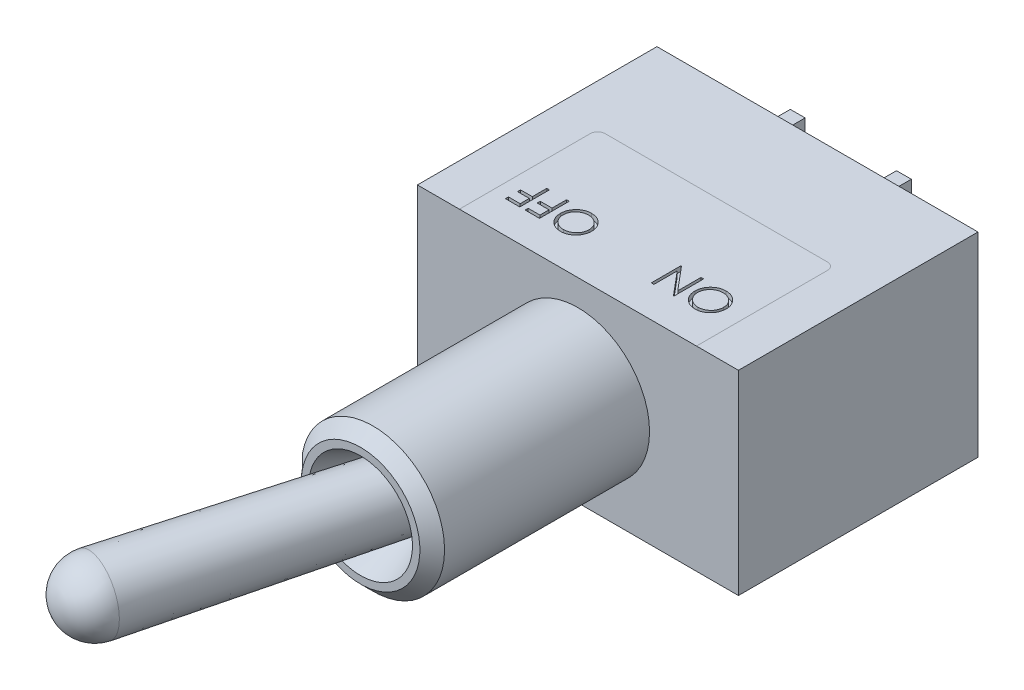
from build123d import *
from build123d.topology import SkipClean

# Parameters (mm, degrees)
SKETCH1_W                = 13
SKETCH1_H                = 7.9
BOSS_EXTRUDE1_DEPTH      = 9.7
SKETCH1_3_R              = 2.9
BOSS_EXTRUDE2_DEPTH      = 8.8
SKETCH10_W               = 1
SKETCH10_H               = 1
CUT_EXTRUDE2_DEPTH       = 13.326495852
CUT_EXTRUDE1_DEPTH       = 0.2
BOSS_EXTRUDE3_DEPTH      = 0.3
BOSS_EXTRUDE3_DEPTH_BACK = 0.3
BOSS_EXTRUDE4_DEPTH      = 0.3
BOSS_EXTRUDE4_DEPTH_BACK = 0.3


with BuildPart() as part:
    # Sketch1 → Boss-Extrude1 (new body)
    with BuildSketch(Plane.XY):
        Rectangle(SKETCH1_W, SKETCH1_H)
    extrude(amount=-BOSS_EXTRUDE1_DEPTH)

    # Sketch1_3 → Boss-Extrude2 (add)
    with BuildSketch(Plane.XY):
        Circle(SKETCH1_3_R)
    extrude(amount=BOSS_EXTRUDE2_DEPTH)

    # Sketch7 → Cut-Revolve1 (revolve, cut)
    with BuildSketch(Plane(origin=(0, 0, 0), x_dir=(1, 0, 0), z_dir=(0, 1, 0))):
        Polygon((2.4, -8.8), (2.9, -8.3), (2.9, -8.8), align=None)
        with BuildLine():
            Line((1.4, -7.2), (2.1, -8.8))
            Line((2.1, -8.8), (0, -8.8))
            Line((0, -8.8), (0, -7.5))
            ThreePointArc((0, -7.5), (0.715891053, -7.424158248), (1.4, -7.2))
        make_face()
    revolve(axis=Axis((0, 0, 0), (0, 0, 1)), mode=Mode.SUBTRACT)

    # Sketch10 → Cut-Extrude2 (cut, through all)
    with BuildSketch(Plane.XY):
        with Locations((-2.9, 0)):
            Rectangle(SKETCH10_W, SKETCH10_H)
    extrude(amount=CUT_EXTRUDE2_DEPTH, mode=Mode.SUBTRACT)

    # Sketch2 → Revolve1 (revolve)
    with SkipClean():  # the faces are left unmerged after this step: merging them gives an invalid solid
        with BuildSketch(Plane(origin=(0, 0, 0), x_dir=(1, 0, 0), z_dir=(0, 1, 0))):
            with BuildLine():
                Line((-3.96418553, -16.58535718), (-1.255703574, -6.863535241))
                Line((-1.255703574, -6.863535241), (-0.983882184, -5.887859866))
                Line((-0.983882184, -5.887859866), (0.258819045, -6.234074174))
                Line((0.258819045, -6.234074174), (0, -7.2))
                Line((0, -7.2), (-2.974236036, -18.3))
                ThreePointArc((-2.974236036, -18.3), (-3.824324938, -17.647703843), (-3.96418553, -16.58535718))
            make_face()
        revolve(axis=Axis((0, 0, 7.2), (-0.2588190451025213, 0, 0.9659258262890682)))

    # Sketch3 → Cut-Extrude1 (cut)
    # profile 1 of 5: a face of its own
    with SkipClean():  # the faces are left unmerged after this step: merging them gives an invalid solid
        with BuildSketch(Plane(origin=(0, 3.95, 0), x_dir=(1, 0, 0), z_dir=(0, 1, 0))):
            with BuildLine():
                add(Edge.make_bspline(
                    [(3.476923077, 1.269230769), (3.454700737, 1.269784093), (3.411054227, 1.270870866), (3.346966785, 1.279464434), (3.285600478, 1.293608936), (3.226918653, 1.313582637), (3.171149539, 1.339480906), (3.118116816, 1.370921984), (3.068002774, 1.408214878), (3.020937029, 1.450474317), (2.978158817, 1.49692627), (2.94093484, 1.546795714), (2.909253765, 1.599078916), (2.883369194, 1.654116364), (2.863029992, 1.711662331), (2.849002855, 1.772059631), (2.840040589, 1.83490719), (2.838992979, 1.877773606), (2.838461538, 1.899519231)],
                    knots=[0, 0, 0, 0, 1.065027606, 2.091802087, 3.093458616, 4.079833113, 5.057734272, 6.036020118, 7.030157768, 8.047461502, 9.064242947, 10.052216774, 11.02588392, 11.989864716, 12.962978571, 13.945936472, 14.957997893, 16, 16, 16, 16], degree=3))
                add(Edge.make_bspline(
                    [(2.838461538, 1.899519231), (2.838993157, 1.921104548), (2.840041038, 1.963651708), (2.849010138, 2.026102226), (2.863092546, 2.086128412), (2.883117579, 2.143590653), (2.909021217, 2.198517163), (2.940752143, 2.250836946), (2.977892488, 2.300851803), (3.020495307, 2.347529881), (3.067017934, 2.390312039), (3.116579271, 2.42813211), (3.169119513, 2.459638397), (3.223818636, 2.48590992), (3.281221016, 2.50580709), (3.34092181, 2.520306518), (3.403259527, 2.529178462), (3.445724032, 2.530233156), (3.467307692, 2.530769231)],
                    knots=[0, 0, 0, 0, 1.043683505, 2.0572211, 3.045299494, 4.022276905, 4.994977706, 5.977452478, 6.97747046, 8.003698437, 9.029677512, 10.031249186, 11.013723958, 11.988083691, 12.9614021, 13.946617861, 14.956316495, 16, 16, 16, 16], degree=3))
                add(Edge.make_bspline(
                    [(3.467307692, 2.530769231), (3.489053216, 2.530238084), (3.531919431, 2.529191051), (3.594845804, 2.520213548), (3.655286124, 2.506180278), (3.713054294, 2.486106187), (3.768169272, 2.460260448), (3.820625727, 2.428499874), (3.870486694, 2.3910744), (3.91724478, 2.348505037), (3.95997535, 2.30207162), (3.997559354, 2.252575357), (4.029136821, 2.200486988), (4.05499347, 2.146021228), (4.075445095, 2.089318864), (4.089402325, 2.030023216), (4.098431444, 1.96846655), (4.099472011, 1.926554736), (4.1, 1.905288462)],
                    knots=[0, 0, 0, 0, 1.053167129, 2.076072758, 3.073341244, 4.055601477, 5.033424535, 6.017524495, 7.021518915, 8.049444456, 9.077120685, 10.074910483, 11.055688766, 12.022980584, 12.991883888, 13.970269434, 14.970104079, 16, 16, 16, 16], degree=3))
                add(Edge.make_bspline(
                    [(4.1, 1.905288462), (4.099816864, 1.891014338), (4.099452904, 1.862646166), (4.095064708, 1.820521435), (4.088709965, 1.779069612), (4.079554983, 1.738430038), (4.067745833, 1.698596078), (4.053193059, 1.659649193), (4.036515575, 1.621268577), (4.016658726, 1.58418468), (3.994994309, 1.548339296), (3.97137144, 1.514180642), (3.945625408, 1.482318884), (3.918123989, 1.452242054), (3.888486503, 1.424463496), (3.857158991, 1.398377574), (3.823977536, 1.374254318), (3.788889659, 1.352600383), (3.752789938, 1.332710982), (3.71541647, 1.316104968), (3.677557796, 1.301427479), (3.638880443, 1.289763228), (3.599473877, 1.280480747), (3.559288836, 1.274173536), (3.51836671, 1.269775589), (3.490797058, 1.269413157), (3.476923077, 1.269230769)],
                    knots=[0, 0, 0, 0, 1.037115869, 2.061148057, 3.07517727, 4.084041727, 5.086514338, 6.092668487, 7.104487461, 8.125783165, 9.147610153, 10.147694368, 11.141876323, 12.122903372, 13.107606018, 14.091946891, 15.084523921, 16.086505767, 17.087268121, 18.077809654, 19.05670789, 20.036870126, 21.011670792, 21.99694167, 22.991993299, 24, 24, 24, 24], degree=3))
            make_face()
            with BuildLine():
                add(Edge.make_bspline(
                    [(3.471634615, 1.392307692), (3.483022661, 1.392445961), (3.505689883, 1.392721177), (3.539384899, 1.396368992), (3.572648837, 1.40152573), (3.605408617, 1.40903429), (3.637693536, 1.41865513), (3.669539428, 1.430535491), (3.700974733, 1.444405007), (3.731711991, 1.460504398), (3.761260316, 1.478550143), (3.789797252, 1.497576351), (3.816232939, 1.518661401), (3.841077991, 1.541023382), (3.864272131, 1.564970188), (3.885818458, 1.590325412), (3.905695744, 1.617203845), (3.923665728, 1.645493495), (3.939657561, 1.675036785), (3.953975734, 1.705268875), (3.965844949, 1.736545082), (3.975247137, 1.768670225), (3.983227439, 1.801502738), (3.988233276, 1.835221504), (3.991916041, 1.869710283), (3.992176137, 1.89301848), (3.992307692, 1.904807692)],
                    knots=[0, 0, 0, 0, 1.008431664, 2.007222653, 2.999229743, 3.989431819, 4.982149843, 5.98167215, 6.998687425, 8.024288174, 9.053028776, 10.065052016, 11.06063401, 12.045759335, 13.024701188, 14.011819507, 14.991481775, 15.984022113, 16.97831254, 17.965966747, 18.945551853, 19.938269878, 20.93007375, 21.936103907, 22.956087853, 24, 24, 24, 24], degree=3))
                add(Edge.make_bspline(
                    [(3.992307692, 1.904807692), (3.991869597, 1.922142917), (3.991007727, 1.956246666), (3.983493686, 2.006229939), (3.971827394, 2.054312747), (3.954913476, 2.100208499), (3.933336435, 2.144121856), (3.907016825, 2.185881922), (3.875713615, 2.225476381), (3.840176831, 2.262610489), (3.801318294, 2.296490768), (3.760076024, 2.326271711), (3.716776314, 2.351336183), (3.671668732, 2.372289519), (3.624368158, 2.38807489), (3.575177864, 2.399329852), (3.524096763, 2.406624513), (3.489287953, 2.407332998), (3.471634615, 2.407692308)],
                    knots=[0, 0, 0, 0, 1.032022337, 2.030307203, 3.003823408, 3.974715386, 4.937372378, 5.913284036, 6.909147208, 7.938749767, 8.970518239, 9.975863271, 10.963918693, 11.946286286, 12.933361397, 13.927862637, 14.949112547, 16, 16, 16, 16], degree=3))
                add(Edge.make_bspline(
                    [(3.471634615, 2.407692308), (3.459768454, 2.40752941), (3.436234291, 2.407206334), (3.401230801, 2.40394771), (3.366854656, 2.398732615), (3.333169482, 2.391186727), (3.300130734, 2.381868113), (3.267839625, 2.370307536), (3.236301172, 2.356455862), (3.2053818, 2.34099386), (3.175751222, 2.323555623), (3.147745925, 2.304395274), (3.121181742, 2.284025846), (3.096382039, 2.26182581), (3.07328473, 2.238081007), (3.052123486, 2.212618508), (3.032255468, 2.185941428), (3.014411522, 2.157658968), (2.998200312, 2.128349444), (2.984302756, 2.098029345), (2.97242672, 2.066890707), (2.962855142, 2.034902801), (2.955350499, 2.002139682), (2.950180528, 1.968553893), (2.946563843, 1.934213591), (2.946291255, 1.91098712), (2.946153846, 1.899278846)],
                    knots=[0, 0, 0, 0, 1.047362266, 2.077233941, 3.100744636, 4.115120168, 5.122788643, 6.129711893, 7.140355774, 8.162227187, 9.180148637, 10.17298275, 11.156396779, 12.133377858, 13.108923632, 14.078087502, 15.054351192, 16.043448276, 17.028082865, 18.009331763, 18.985518559, 19.968016174, 20.954783108, 21.950335389, 22.966780876, 24, 24, 24, 24], degree=3))
                add(Edge.make_bspline(
                    [(2.946153846, 1.899278846), (2.946291371, 1.887650673), (2.946564176, 1.86458405), (2.950178738, 1.830483198), (2.955356187, 1.79713924), (2.962817687, 1.764683079), (2.972434882, 1.733106442), (2.984293396, 1.702438987), (2.998276923, 1.672566456), (3.014325475, 1.643562724), (3.032365117, 1.615731284), (3.052077684, 1.589125117), (3.073801996, 1.564241639), (3.096923046, 1.540474962), (3.12199671, 1.518300451), (3.149027384, 1.497803857), (3.177341962, 1.478061387), (3.207581059, 1.460589919), (3.238676041, 1.444371097), (3.270615673, 1.430545466), (3.303000551, 1.418602359), (3.335873929, 1.409075725), (3.36917902, 1.401518436), (3.402925078, 1.396370861), (3.437099574, 1.392720785), (3.460086404, 1.392445827), (3.471634615, 1.392307692)],
                    knots=[0, 0, 0, 0, 1.02988216, 2.042960975, 3.035124439, 4.018561492, 4.99104521, 5.957523397, 6.929462691, 7.91146347, 8.892205782, 9.866320947, 10.842813644, 11.816825305, 12.802668543, 13.805243666, 14.821427616, 15.858893029, 16.897256944, 17.927432741, 18.940436917, 19.95373962, 20.957947499, 21.96413624, 22.977215056, 24, 24, 24, 24], degree=3))
            make_face(mode=Mode.SUBTRACT)
        # profile 2 of 5: a face of its own
        with BuildSketch(Plane(origin=(0, 3.95, 0), x_dir=(1, 0, 0), z_dir=(0, 1, 0))):
            Polygon((2.592307692, 2.5), (2.592307692, 1.3), (2.569711538, 1.3), (1.776923077, 2.244471154), (1.776923077, 1.3), (1.669230769, 1.3), (1.669230769, 2.5), (1.69375, 2.5), (2.484615385, 1.557692308), (2.484615385, 2.5), align=None)
        # profile 3 of 5: a face of its own
        with BuildSketch(Plane(origin=(0, 3.95, 0), x_dir=(1, 0, 0), z_dir=(0, 1, 0))):
            with BuildLine():
                add(Edge.make_bspline(
                    [(-1.969230769, 1.269230769), (-1.991453109, 1.269784093), (-2.035099619, 1.270870866), (-2.099187061, 1.279464434), (-2.160553369, 1.293608936), (-2.219235193, 1.313582637), (-2.275004307, 1.339480906), (-2.32803703, 1.370921984), (-2.378151072, 1.408214878), (-2.425216818, 1.450474317), (-2.467995029, 1.49692627), (-2.505219006, 1.546795714), (-2.536900081, 1.599078916), (-2.562784653, 1.654116364), (-2.583123854, 1.711662331), (-2.597150991, 1.772059631), (-2.606113257, 1.83490719), (-2.607160867, 1.877773606), (-2.607692308, 1.899519231)],
                    knots=[0, 0, 0, 0, 1.065027606, 2.091802087, 3.093458616, 4.079833113, 5.057734272, 6.036020118, 7.030157768, 8.047461502, 9.064242947, 10.052216774, 11.02588392, 11.989864716, 12.962978571, 13.945936472, 14.957997893, 16, 16, 16, 16], degree=3))
                add(Edge.make_bspline(
                    [(-2.607692308, 1.899519231), (-2.607160689, 1.921104548), (-2.606112808, 1.963651708), (-2.597143709, 2.026102226), (-2.5830613, 2.086128412), (-2.563036267, 2.143590653), (-2.537132629, 2.198517163), (-2.505401704, 2.250836946), (-2.468261358, 2.300851803), (-2.425658539, 2.347529881), (-2.379135912, 2.390312039), (-2.329574575, 2.42813211), (-2.277034333, 2.459638397), (-2.222335211, 2.48590992), (-2.16493283, 2.50580709), (-2.105232036, 2.520306518), (-2.042894319, 2.529178462), (-2.000429815, 2.530233156), (-1.978846154, 2.530769231)],
                    knots=[0, 0, 0, 0, 1.043683505, 2.0572211, 3.045299494, 4.022276905, 4.994977706, 5.977452478, 6.97747046, 8.003698437, 9.029677512, 10.031249186, 11.013723958, 11.988083691, 12.9614021, 13.946617861, 14.956316495, 16, 16, 16, 16], degree=3))
                add(Edge.make_bspline(
                    [(-1.978846154, 2.530769231), (-1.957100631, 2.530238084), (-1.914234416, 2.529191051), (-1.851308042, 2.520213548), (-1.790867722, 2.506180278), (-1.733099552, 2.486106187), (-1.677984574, 2.460260448), (-1.625528119, 2.428499874), (-1.575667152, 2.3910744), (-1.528909066, 2.348505037), (-1.486178496, 2.30207162), (-1.448594492, 2.252575357), (-1.417017025, 2.200486988), (-1.391160376, 2.146021228), (-1.370708751, 2.089318864), (-1.356751521, 2.030023216), (-1.347722402, 1.96846655), (-1.346681835, 1.926554736), (-1.346153846, 1.905288462)],
                    knots=[0, 0, 0, 0, 1.053167129, 2.076072758, 3.073341244, 4.055601477, 5.033424535, 6.017524495, 7.021518915, 8.049444456, 9.077120685, 10.074910483, 11.055688766, 12.022980584, 12.991883888, 13.970269434, 14.970104079, 16, 16, 16, 16], degree=3))
                add(Edge.make_bspline(
                    [(-1.346153846, 1.905288462), (-1.346336982, 1.891014338), (-1.346700942, 1.862646166), (-1.351089139, 1.820521435), (-1.357443882, 1.779069612), (-1.366598863, 1.738430038), (-1.378408013, 1.698596078), (-1.392960787, 1.659649193), (-1.409638272, 1.621268577), (-1.42949512, 1.58418468), (-1.451159537, 1.548339296), (-1.474782406, 1.514180642), (-1.500528438, 1.482318884), (-1.528029857, 1.452242054), (-1.557667344, 1.424463496), (-1.588994855, 1.398377574), (-1.62217631, 1.374254318), (-1.657264188, 1.352600383), (-1.693363908, 1.332710982), (-1.730737376, 1.316104968), (-1.76859605, 1.301427479), (-1.807273403, 1.289763228), (-1.846679969, 1.280480747), (-1.88686501, 1.274173536), (-1.927787136, 1.269775589), (-1.955356788, 1.269413157), (-1.969230769, 1.269230769)],
                    knots=[0, 0, 0, 0, 1.037115869, 2.061148057, 3.07517727, 4.084041727, 5.086514338, 6.092668487, 7.104487461, 8.125783165, 9.147610153, 10.147694368, 11.141876323, 12.122903372, 13.107606018, 14.091946891, 15.084523921, 16.086505767, 17.087268121, 18.077809654, 19.05670789, 20.036870126, 21.011670792, 21.99694167, 22.991993299, 24, 24, 24, 24], degree=3))
            make_face()
            with BuildLine():
                add(Edge.make_bspline(
                    [(-1.974519231, 1.392307692), (-1.963131185, 1.392445961), (-1.940463963, 1.392721177), (-1.906768947, 1.396368992), (-1.873505009, 1.40152573), (-1.840745229, 1.40903429), (-1.80846031, 1.41865513), (-1.776614418, 1.430535491), (-1.745179113, 1.444405007), (-1.714441855, 1.460504398), (-1.68489353, 1.478550143), (-1.656356594, 1.497576351), (-1.629920907, 1.518661401), (-1.605075855, 1.541023382), (-1.581881715, 1.564970188), (-1.560335388, 1.590325412), (-1.540458103, 1.617203845), (-1.522488118, 1.645493495), (-1.506496285, 1.675036785), (-1.492178112, 1.705268875), (-1.480308897, 1.736545082), (-1.47090671, 1.768670225), (-1.462926407, 1.801502738), (-1.45792057, 1.835221504), (-1.454237806, 1.869710283), (-1.45397771, 1.89301848), (-1.453846154, 1.904807692)],
                    knots=[0, 0, 0, 0, 1.008431664, 2.007222653, 2.999229743, 3.989431819, 4.982149843, 5.98167215, 6.998687425, 8.024288174, 9.053028776, 10.065052016, 11.06063401, 12.045759335, 13.024701188, 14.011819507, 14.991481775, 15.984022113, 16.97831254, 17.965966747, 18.945551853, 19.938269878, 20.93007375, 21.936103907, 22.956087853, 24, 24, 24, 24], degree=3))
                add(Edge.make_bspline(
                    [(-1.453846154, 1.904807692), (-1.454284249, 1.922142917), (-1.455146119, 1.956246666), (-1.46266016, 2.006229939), (-1.474326452, 2.054312747), (-1.491240371, 2.100208499), (-1.512817412, 2.144121856), (-1.539137021, 2.185881922), (-1.570440231, 2.225476381), (-1.605977015, 2.262610489), (-1.644835552, 2.296490768), (-1.686077822, 2.326271711), (-1.729377532, 2.351336183), (-1.774485114, 2.372289519), (-1.821785688, 2.38807489), (-1.870975982, 2.399329852), (-1.922057083, 2.406624513), (-1.956865893, 2.407332998), (-1.974519231, 2.407692308)],
                    knots=[0, 0, 0, 0, 1.032022337, 2.030307203, 3.003823408, 3.974715386, 4.937372378, 5.913284036, 6.909147208, 7.938749767, 8.970518239, 9.975863271, 10.963918693, 11.946286286, 12.933361397, 13.927862637, 14.949112547, 16, 16, 16, 16], degree=3))
                add(Edge.make_bspline(
                    [(-1.974519231, 2.407692308), (-1.986385393, 2.40752941), (-2.009919556, 2.407206334), (-2.044923045, 2.40394771), (-2.07929919, 2.398732615), (-2.112984364, 2.391186727), (-2.146023112, 2.381868113), (-2.178314221, 2.370307536), (-2.209852674, 2.356455862), (-2.240772046, 2.34099386), (-2.270402624, 2.323555623), (-2.298407921, 2.304395274), (-2.324972104, 2.284025846), (-2.349771807, 2.26182581), (-2.372869116, 2.238081007), (-2.394030361, 2.212618508), (-2.413898378, 2.185941428), (-2.431742324, 2.157658968), (-2.447953534, 2.128349444), (-2.46185109, 2.098029345), (-2.473727126, 2.066890707), (-2.483298704, 2.034902801), (-2.490803347, 2.002139682), (-2.495973319, 1.968553893), (-2.499590004, 1.934213591), (-2.499862591, 1.91098712), (-2.5, 1.899278846)],
                    knots=[0, 0, 0, 0, 1.047362266, 2.077233941, 3.100744636, 4.115120168, 5.122788643, 6.129711893, 7.140355774, 8.162227187, 9.180148637, 10.17298275, 11.156396779, 12.133377858, 13.108923632, 14.078087502, 15.054351192, 16.043448276, 17.028082865, 18.009331763, 18.985518559, 19.968016174, 20.954783108, 21.950335389, 22.966780876, 24, 24, 24, 24], degree=3))
                add(Edge.make_bspline(
                    [(-2.5, 1.899278846), (-2.499862476, 1.887650673), (-2.49958967, 1.86458405), (-2.495975108, 1.830483198), (-2.49079766, 1.79713924), (-2.48333616, 1.764683079), (-2.473718964, 1.733106442), (-2.46186045, 1.702438987), (-2.447876923, 1.672566456), (-2.431828371, 1.643562724), (-2.413788729, 1.615731284), (-2.394076162, 1.589125117), (-2.372351851, 1.564241639), (-2.3492308, 1.540474962), (-2.324157136, 1.518300451), (-2.297126462, 1.497803857), (-2.268811884, 1.478061387), (-2.238572788, 1.460589919), (-2.207477805, 1.444371097), (-2.175538173, 1.430545466), (-2.143153295, 1.418602359), (-2.110279917, 1.409075725), (-2.076974826, 1.401518436), (-2.043228768, 1.396370861), (-2.009054272, 1.392720785), (-1.986067442, 1.392445827), (-1.974519231, 1.392307692)],
                    knots=[0, 0, 0, 0, 1.02988216, 2.042960975, 3.035124439, 4.018561492, 4.99104521, 5.957523397, 6.929462691, 7.91146347, 8.892205782, 9.866320947, 10.842813644, 11.816825305, 12.802668543, 13.805243666, 14.821427616, 15.858893029, 16.897256944, 17.927432741, 18.940436917, 19.95373962, 20.957947499, 21.96413624, 22.977215056, 24, 24, 24, 24], degree=3))
            make_face(mode=Mode.SUBTRACT)
        # profile 4 of 5: a face of its own
        with BuildSketch(Plane(origin=(0, 3.95, 0), x_dir=(1, 0, 0), z_dir=(0, 1, 0))):
            Polygon((-2.853846154, 1.3), (-3.438461538, 1.3), (-3.438461538, 1.423076923), (-2.961538462, 1.423076923), (-2.961538462, 1.792307692), (-3.438461538, 1.792307692), (-3.438461538, 1.915384615), (-2.961538462, 1.915384615), (-2.961538462, 2.5), (-2.853846154, 2.5), align=None)
        # profile 5 of 5: a face of its own
        with BuildSketch(Plane(origin=(0, 3.95, 0), x_dir=(1, 0, 0), z_dir=(0, 1, 0))):
            Polygon((-3.653846154, 1.3), (-4.238461538, 1.3), (-4.238461538, 1.423076923), (-3.761538462, 1.423076923), (-3.761538462, 1.792307692), (-4.238461538, 1.792307692), (-4.238461538, 1.915384615), (-3.761538462, 1.915384615), (-3.761538462, 2.5), (-3.653846154, 2.5), align=None)
        extrude(amount=-CUT_EXTRUDE1_DEPTH, mode=Mode.SUBTRACT)

    # Sketch4 → Boss-Extrude3 (add, two sides: drawn at the far end of the back side and taken through both)
    with SkipClean():  # the faces are left unmerged after this step: merging them gives an invalid solid
        with BuildSketch(Plane(origin=(0, 0, 0), x_dir=(0, 0, -1), z_dir=(1, 0, 0)).offset(-BOSS_EXTRUDE3_DEPTH_BACK)):
            Polygon((9.7, 1.6), (9.7, -1.6), (9.75, -1.6), (10.2, -0.95), (13.2, -0.95), (13.2, 0.95), (10.2, 0.95), (9.75, 1.6), align=None)
            with BuildLine():
                Line((12.05, 0.55), (12.25, 0.55))
                ThreePointArc((12.25, 0.55), (12.8, 0), (12.25, -0.55))
                Line((12.25, -0.55), (12.05, -0.55))
                ThreePointArc((12.05, -0.55), (11.5, 0), (12.05, 0.55))
            make_face(mode=Mode.SUBTRACT)
        extrude(amount=BOSS_EXTRUDE3_DEPTH + BOSS_EXTRUDE3_DEPTH_BACK)

    # Sketch5 → Boss-Extrude4 (add, two sides: drawn at the far end of the back side and taken through both)
    with SkipClean():  # the faces are left unmerged after this step: merging them gives an invalid solid
        with BuildSketch(Plane(origin=(-4.3, 0, 0), x_dir=(0, 0, -1), z_dir=(1, 0, 0)).offset(-BOSS_EXTRUDE4_DEPTH_BACK)):
            Polygon((13.2, -0.95), (13.2, 0.95), (10.2, 0.95), (9.75, 1.6), (9.7, 1.6), (9.7, -1.6), (9.75, -1.6), (10.2, -0.95), align=None)
            with BuildLine():
                Line((12.05, -0.55), (12.25, -0.55))
                ThreePointArc((12.25, -0.55), (12.8, 0), (12.25, 0.55))
                Line((12.25, 0.55), (12.05, 0.55))
                ThreePointArc((12.05, 0.55), (11.5, 0), (12.05, -0.55))
            make_face(mode=Mode.SUBTRACT)
        extrude(amount=BOSS_EXTRUDE4_DEPTH + BOSS_EXTRUDE4_DEPTH_BACK)


solid = part.part
